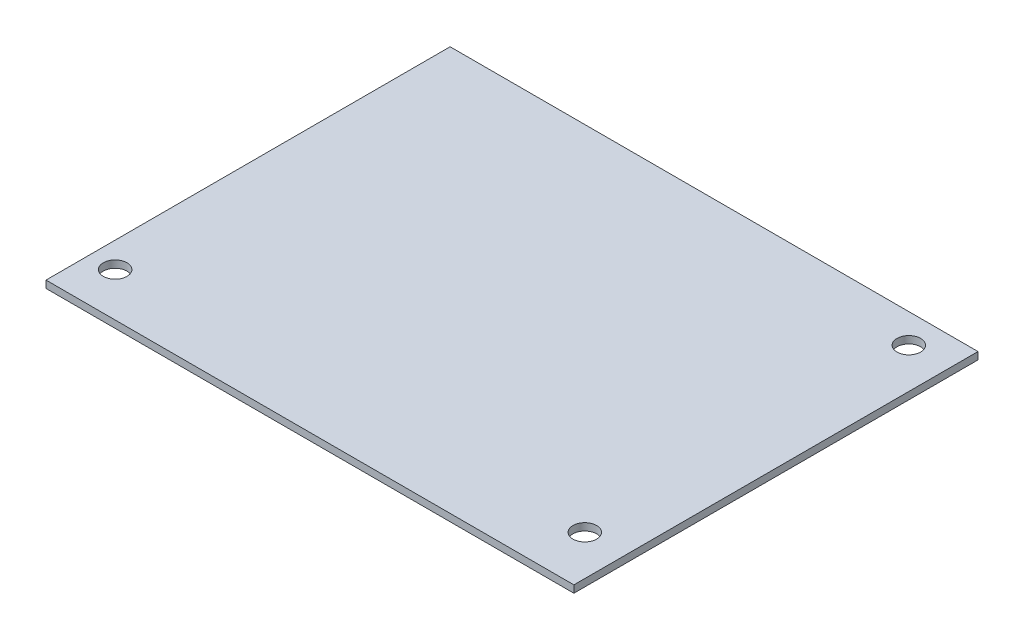
from build123d import *

# Parameters (mm, degrees)
SKETCH1_W           = 145
SKETCH1_H           = 111
SKETCH1_R           = 3.25
BOSS_EXTRUDE1_DEPTH = 2


with BuildPart() as part:
    # Sketch1 → Boss-Extrude1 (new body)
    with BuildSketch(Plane(origin=(0, 0, 0), x_dir=(1, 0, 0), z_dir=(0, 1, 0))):
        with Locations((-72.5, 55.5)):
            Rectangle(SKETCH1_W, SKETCH1_H)
        with Locations((-138, 12)):
            Circle(SKETCH1_R, mode=Mode.SUBTRACT)
        with Locations((-11, 14)):
            Circle(SKETCH1_R, mode=Mode.SUBTRACT)
        with Locations((-11, 103)):
            Circle(SKETCH1_R, mode=Mode.SUBTRACT)
    extrude(amount=BOSS_EXTRUDE1_DEPTH)


solid = part.part
